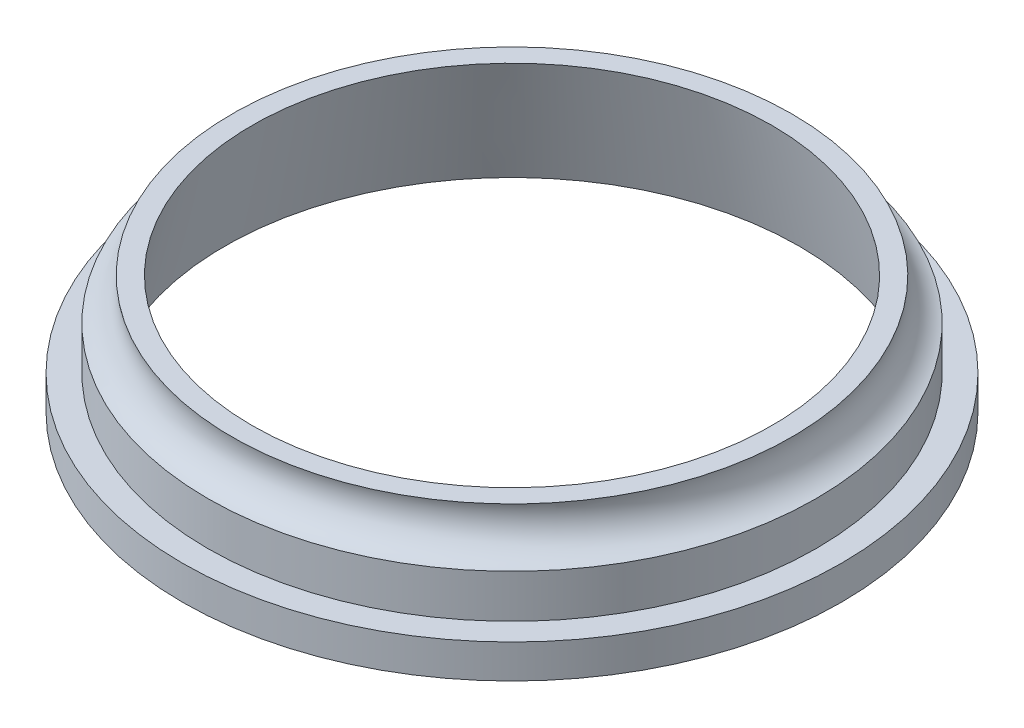
from build123d import *


with BuildPart() as part:
    # Esquisse1 → Révolution1 (revolve)
    with BuildSketch(Plane.XY, mode=Mode.PRIVATE) as r_volution1_sk:
        with BuildLine():
            Line((17, -6.5), (19.5, -6.5))
            Line((19.5, -6.5), (19.5, -4.5))
            Line((19.5, -4.5), (18, -4.5))
            Line((18, -4.5), (18, -1.936491673))
            ThreePointArc((18, -1.936491673), (16.777140216, -1.015753003), (16.563508327, 0.5))
            Line((16.563508327, 0.5), (15.383922662, 0.5))
            Line((15.383922662, 0.5), (17, -6.5))
        make_face()
    revolve(r_volution1_sk.sketch.rotate(Axis((0, -11.232892416, 0), (0, 1, 0)), 90), axis=Axis((0, -11.232892416, 0), (0, 1, 0)))  # turned: the seam where the file's is


solid = part.part
